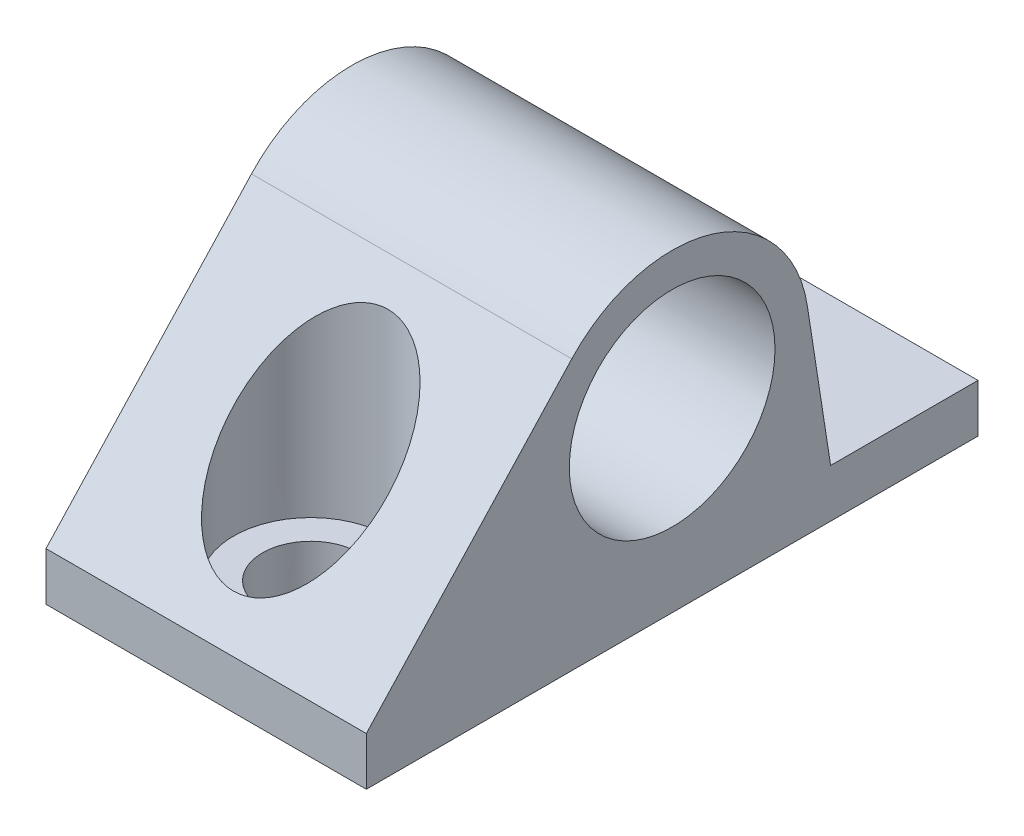
from build123d import *

# Parameters (mm, degrees)
BOSS_EXTRUDE1_DEPTH = 38
SKETCH2_R           = 6.39
BOSS_EXTRUDE2_DEPTH = 19.9


with BuildPart() as part:
    # Sketch1 → Boss-Extrude1 (new body)
    with BuildSketch(Plane.XY):
        Polygon((101.60617691, 195.484265545), (108.51617691, 195.484265545), (114.604851948, 195.484265545), (121.50617691, 195.484265545), (121.50617691, 198.484265545), (101.60617691, 198.484265545), align=None)
    extrude(amount=-BOSS_EXTRUDE1_DEPTH)

    # Sketch2 → Boss-Extrude2 (add)
    with BuildSketch(Plane.ZY.offset(-101.60617691)):
        with BuildLine():
            Line((-28.843974353, 198.484265545), (-27.399359103, 207.788399993))
            ThreePointArc((-27.399359103, 207.788399993), (-21.484497631, 214.613058291), (-12.764937605, 212.261288734))
            Line((-12.764937605, 212.261288734), (0, 198.484265545))
            Line((0, 198.484265545), (-28.843974353, 198.484265545))
        make_face()
        with Locations((-19, 206.484265545)):
            Circle(SKETCH2_R, mode=Mode.SUBTRACT)
    extrude(amount=-BOSS_EXTRUDE2_DEPTH)

    # Sketch3 → Cut-Revolve1 (revolve, cut)
    with BuildSketch(Plane.ZY.offset(-111.55617691)):
        Polygon((-26.7, 211.670017018), (-26.7, 198.484265545), (-28.5, 198.484265545), (-28.5, 189.906068288), (-31.5, 189.906068288), (-31.5, 211.670017018), align=None)
    cut_revolve1 = revolve(axis=Axis((111.55617691, 189.906068288, -31.5), (0, 1, 0)), mode=Mode.SUBTRACT)

    # Mirror1: Cut-Revolve1 across plane
    add(cut_revolve1.mirror(Plane(origin=(0, 0, -19), x_dir=(1, 0, 0), z_dir=(0, 0, -1))), mode=Mode.SUBTRACT)


solid = part.part
